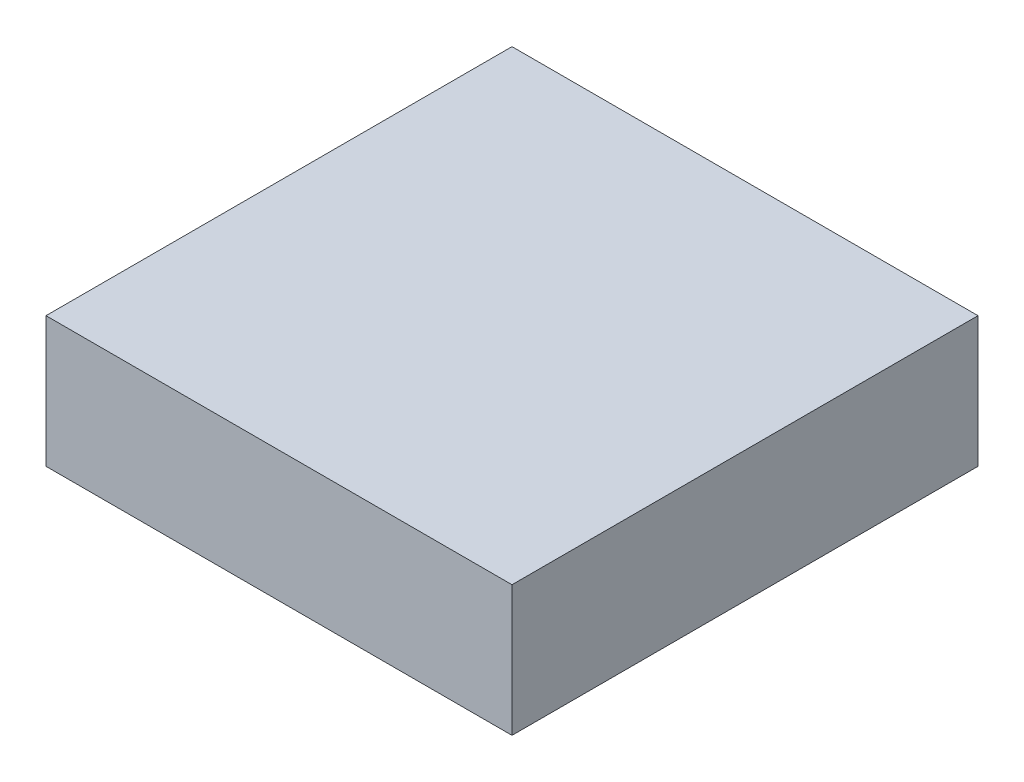
from build123d import *

# Parameters (mm, degrees)
SKETCH1_W           = 45
SKETCH1_H           = 45
BOSS_EXTRUDE1_DEPTH = 12.6


with BuildPart() as part:
    # Sketch1 → Boss-Extrude1 (new body)
    with BuildSketch(Plane(origin=(0, 0, 0), x_dir=(1, 0, 0), z_dir=(0, 1, 0))):
        Rectangle(SKETCH1_W, SKETCH1_H)
    extrude(amount=BOSS_EXTRUDE1_DEPTH)


solid = part.part
